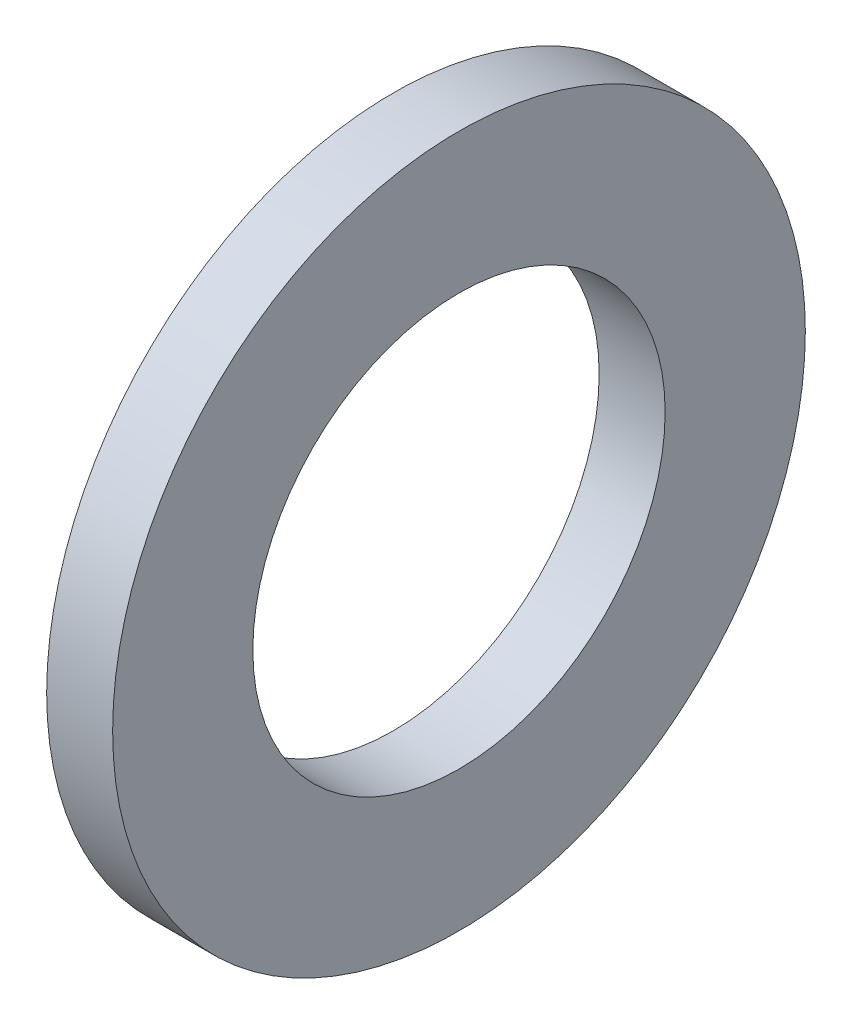
from build123d import *

# Parameters (mm, degrees)
SKETCH_1_R      = 21
SKETCH_1_R_2    = 12.5
EXTRUDE_1_DEPTH = 4


with BuildPart() as part:
    # 草图1 → 凸台-拉伸1 (new body)
    with BuildSketch(Plane(origin=(0, 0, 0), x_dir=(0, 0, -1), z_dir=(1, 0, 0))):
        Circle(SKETCH_1_R)
        Circle(SKETCH_1_R_2, mode=Mode.SUBTRACT)
    extrude(amount=EXTRUDE_1_DEPTH)


solid = part.part
